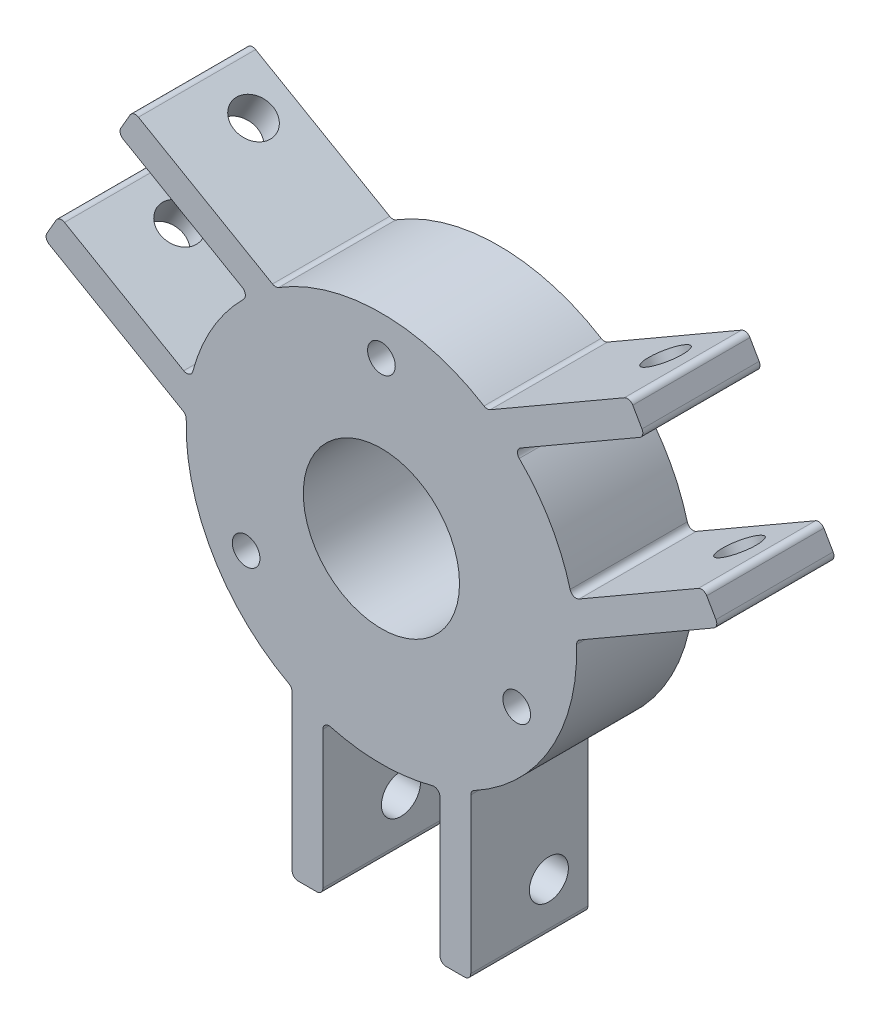
from build123d import *

# Parameters (mm, degrees)
ESQUISSE1_R             = 31.75
ESQUISSE1_R_2           = 12.7
ESQUISSE1_R_3           = 2.25
BOSS_EXTRU_1_DEPTH      = 19.05
BOSS_EXTRU_2_DEPTH      = 19.05
ESQUISSE3_R             = 3.175
ENL_V_MAT_EXTRU_1_DEPTH = 90.603345812
ESQUISSE4_R             = 3.175
ENL_V_MAT_EXTRU_2_DEPTH = 90.603345812
ESQUISSE5_R             = 3.175
ENL_V_MAT_EXTRU_3_DEPTH = 70.418897208
CONG_1_R                = 1


with BuildPart() as part:
    # Esquisse1 → Boss.-Extru.1 (new body)
    with BuildSketch(Plane.XY):
        Circle(ESQUISSE1_R)
        Circle(ESQUISSE1_R_2, mode=Mode.SUBTRACT)
        with Locations((0, 25.4)):
            Circle(ESQUISSE1_R_3, mode=Mode.SUBTRACT)
        with Locations((-21.997045256, -12.7)):
            Circle(ESQUISSE1_R_3, mode=Mode.SUBTRACT)
        with Locations((21.997045256, -12.7)):
            Circle(ESQUISSE1_R_3, mode=Mode.SUBTRACT)
    extrude(amount=BOSS_EXTRU_1_DEPTH)

    # Esquisse2 → Boss.-Extru.2 (add)
    with BuildSketch(Plane.XY.offset(19.05)):
        Polygon((42.868897208, 35.748891971), (21.467304731, 23.392676794), (17.187758818, 26.6953825), (40.368897208, 40.07901899), align=None)
        Polygon((30.992304731, 6.894892851), (31.712758818, 1.53734452), (54.893897208, 14.92098101), (52.393897208, 19.251108029), align=None)
        Polygon((14.525, -55), (14.525, -28.23272702), (9.525, -30.287569645), (9.525, -55), align=None)
        Polygon((-9.525, -30.287569645), (-14.525, -28.23272702), (-14.525, -55), (-9.525, -55), align=None)
        Polygon((-54.893897208, 14.92098101), (-31.712758818, 1.53734452), (-30.992304731, 6.894892851), (-52.393897208, 19.251108029), align=None)
        Polygon((-21.467304731, 23.392676794), (-17.187758818, 26.6953825), (-40.368897208, 40.07901899), (-42.868897208, 35.748891971), align=None)
    extrude(amount=-BOSS_EXTRU_2_DEPTH)

    # Esquisse3 → Enlèv. mat.-Extru.1 (cut, through all)
    with BuildSketch(Plane(origin=(7.2625, 12.57901899, 0), x_dir=(0.866025404, -0.5, 0), z_dir=(0.5, 0.866025404, 0))):
        with Locations((-47.0625, -6.35)):
            Circle(ESQUISSE3_R)
    extrude(amount=-ENL_V_MAT_EXTRU_1_DEPTH, mode=Mode.SUBTRACT)

    # Esquisse4 → Enlèv. mat.-Extru.2 (cut, through all)
    with BuildSketch(Plane(origin=(-7.2625, 12.57901899, 0), x_dir=(0.866025404, 0.5, 0), z_dir=(-0.5, 0.866025404, 0))):
        with Locations((47.0625, -6.35)):
            Circle(ESQUISSE4_R)
    extrude(amount=-ENL_V_MAT_EXTRU_2_DEPTH, mode=Mode.SUBTRACT)

    # Esquisse5 → Enlèv. mat.-Extru.3 (cut, through all)
    with BuildSketch(Plane(origin=(14.525, 0, 0), x_dir=(0, 0, -1), z_dir=(1, 0, 0))):
        with Locations((-6.35, -47.0625)):
            Circle(ESQUISSE5_R)
    extrude(amount=-ENL_V_MAT_EXTRU_3_DEPTH, mode=Mode.SUBTRACT)

    # Congé1
    cong_1_edges = [part.edges().sort_by_distance(p)[0] for p in [
        (40.368897208, 40.07901899, 9.525),
        (42.868897208, 35.748891971, 9.525),
        (21.467304731, 23.392676794, 9.525),
        (17.187758818, 26.6953825, 9.525),
        (30.992304731, 6.894892851, 9.525),
        (52.393897208, 19.251108029, 9.525),
        (54.893897208, 14.92098101, 9.525),
        (31.712758818, 1.53734452, 9.525),
        (14.525, -55, 9.525),
        (9.525, -55, 9.525),
        (9.525, -30.287569645, 9.525),
        (14.525, -28.23272702, 9.525),
        (-9.525, -30.287569645, 9.525),
        (-9.525, -55, 9.525),
        (-14.525, -55, 9.525),
        (-14.525, -28.23272702, 9.525),
        (-54.893897208, 14.92098101, 9.525),
        (-52.393897208, 19.251108029, 9.525),
        (-30.992304731, 6.894892851, 9.525),
        (-31.712758818, 1.53734452, 9.525),
        (-21.467304731, 23.392676794, 9.525),
        (-42.868897208, 35.748891971, 9.525),
        (-40.368897208, 40.07901899, 9.525),
        (-17.187758818, 26.6953825, 9.525),
    ]]
    fillet(cong_1_edges, radius=CONG_1_R)


solid = part.part
